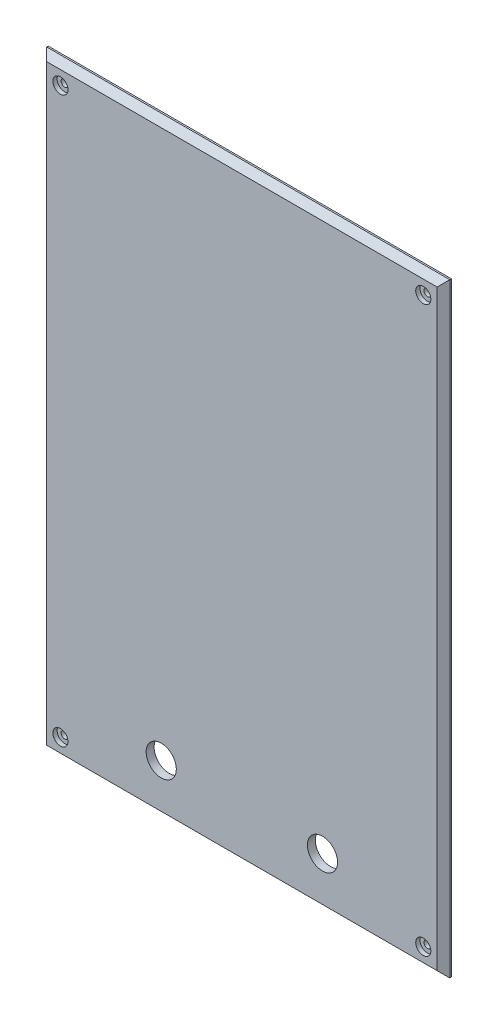
from build123d import *

# Parameters (mm, degrees)
SKETCH1_W                                           = 254
SKETCH1_H                                           = 381
BOSS_EXTRUDE1_DEPTH                                 = 5
CHAMFER1_SIZE                                       = 4
CBORE_FOR_8_BINDING_HEAD_MACHINE_SCREW1_D           = 4.4958
CBORE_FOR_8_BINDING_HEAD_MACHINE_SCREW1_CBORE_D     = 9.525
CBORE_FOR_8_BINDING_HEAD_MACHINE_SCREW1_CBORE_DEPTH = 2.667
LPATTERN1_COUNT                                     = 2
LPATTERN1_PITCH                                     = 355.6
LPATTERN1_COUNT_DIR2                                = 2
LPATTERN1_PITCH_DIR2                                = 228.6
F_19_0_19_DIAMETER_HOLE1_D                          = 19


with BuildPart() as part:
    # Sketch1 → Boss-Extrude1 (new body)
    with BuildSketch(Plane.XY):
        Rectangle(SKETCH1_W, SKETCH1_H)
    extrude(amount=BOSS_EXTRUDE1_DEPTH)

    # Chamfer1
    chamfer1_edges = [part.edges().sort_by_distance(p)[0] for p in [
        (127, 0, 5),
        (0, 190.5, 5),
        (-127, 0, 5),
        (0, -190.5, 5),
    ]]
    chamfer(chamfer1_edges, length=CHAMFER1_SIZE)

    # CBORE for #8 Binding Head Machine Screw1 (through all)
    with Locations(Plane.XY.offset(5)):
        with Locations((-114.3, 177.8)):
            cbore_for_8_binding_head_machine_screw1 = CounterBoreHole(CBORE_FOR_8_BINDING_HEAD_MACHINE_SCREW1_D / 2, CBORE_FOR_8_BINDING_HEAD_MACHINE_SCREW1_CBORE_D / 2, CBORE_FOR_8_BINDING_HEAD_MACHINE_SCREW1_CBORE_DEPTH)

    # LPattern1: CBORE for _8 Binding Head Machine Screw1 2 × 2
    with Locations(*[(j * LPATTERN1_PITCH_DIR2, -i * LPATTERN1_PITCH, 0) for i in range(LPATTERN1_COUNT) for j in range(LPATTERN1_COUNT_DIR2) if (i, j) != (0, 0)]):
        add(cbore_for_8_binding_head_machine_screw1, mode=Mode.SUBTRACT)

    # Ø19.0 (19) Diameter Hole1 (through all)
    with Locations(Plane.XY.offset(5)):
        with Locations((-50.8, -158.75), (50.8, -158.75)):
            Hole(F_19_0_19_DIAMETER_HOLE1_D / 2)


solid = part.part
